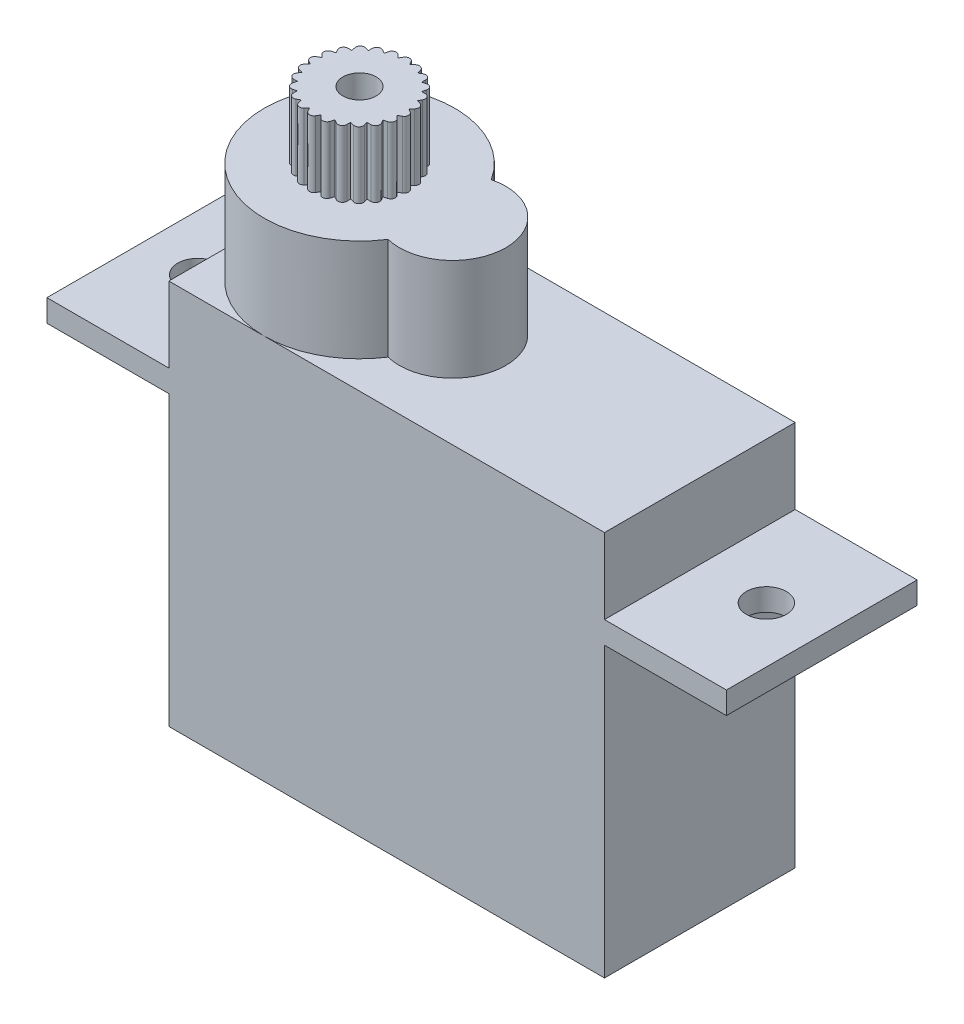
from build123d import *

# Parameters (mm, degrees)
RESSALTO_EXTRUS_O1_DEPTH = 8.6
ESBO_O2_R                = 0.9
CORTE_EXTRUS_O1_DEPTH    = 15
ESBO_O3_R                = 4.3
ESBO_O3_R_2              = 2.4
RESSALTO_EXTRUS_O3_DEPTH = 4.6
ESBO_O4_R                = 1.9
ESBO_O4_R_2              = 0.75
RESSALTO_EXTRUS_O4_DEPTH = 3
RESSALTO_EXTRUS_O5_DEPTH = 3
PADR_OCIRCULAR1_COUNT    = 24


with BuildPart() as part:
    # Esboço1 → Ressalto-extrusão1 (new body)
    with BuildSketch(Plane.XY):
        Polygon((0, 0), (0, 13), (-5.5, 13), (-5.5, 14), (0, 14), (0, 17.4), (19.65, 17.4), (19.65, 14), (25.15, 14), (25.15, 13), (19.65, 13), (19.65, 0), align=None)
    extrude(amount=RESSALTO_EXTRUS_O1_DEPTH)

    # Esboço2 → Corte-extrusão1 (cut, through all)
    with BuildSketch(Plane(origin=(0, 14, 0), x_dir=(1, 0, 0), z_dir=(0, 1, 0))):
        with Locations((-3, -4.3)):
            Circle(ESBO_O2_R)
        with Locations((22.65, -4.3)):
            Circle(ESBO_O2_R)
    extrude(amount=-CORTE_EXTRUS_O1_DEPTH, mode=Mode.SUBTRACT)

    # Esboço3 → Ressalto-extrusão3 (add)
    with BuildSketch(Plane(origin=(0, 17.4, 0), x_dir=(1, 0, 0), z_dir=(0, 1, 0))):
        with Locations((4.3, -4.3)):
            Circle(ESBO_O3_R)
        with Locations((8.5, -4.3)):
            Circle(ESBO_O3_R_2)
    extrude(amount=RESSALTO_EXTRUS_O3_DEPTH)

    # Esboço4 → Ressalto-extrusão4 (add)
    with BuildSketch(Plane(origin=(0, 22, 0), x_dir=(1, 0, 0), z_dir=(0, 1, 0))):
        with Locations((4.3, -4.3)):
            Circle(ESBO_O4_R)
        with Locations((4.3, -4.3)):
            Circle(ESBO_O4_R_2, mode=Mode.SUBTRACT)
    extrude(amount=RESSALTO_EXTRUS_O4_DEPTH)

    # Esboço5 → Ressalto-extrusão5 (add)
    with BuildSketch(Plane(origin=(0, 25, 0), x_dir=(1, 0, 0), z_dir=(0, 1, 0))):
        with BuildLine():
            Line((3.996143779, -2.424454374), (4.147072388, -2.164733177))
            ThreePointArc((4.147072388, -2.164733177), (4.320558883, -2.065222191), (4.493481171, -2.16571041))
            Line((4.493481171, -2.16571041), (4.646102398, -2.431788789))
            Line((4.646102398, -2.431788789), (3.996143779, -2.424454374))
        make_face()
    ressalto_extrus_o5 = extrude(amount=-RESSALTO_EXTRUS_O5_DEPTH)

    # PadrãoCircular1: Ressalto-extrusão5 ×24 about axis
    padr_ocircular1_axis = Axis((4.3, 0, 4.3), (0, 1, 0))
    for i in range(1, PADR_OCIRCULAR1_COUNT):
        add(ressalto_extrus_o5.rotate(padr_ocircular1_axis, i * 360 / PADR_OCIRCULAR1_COUNT))


solid = part.part
